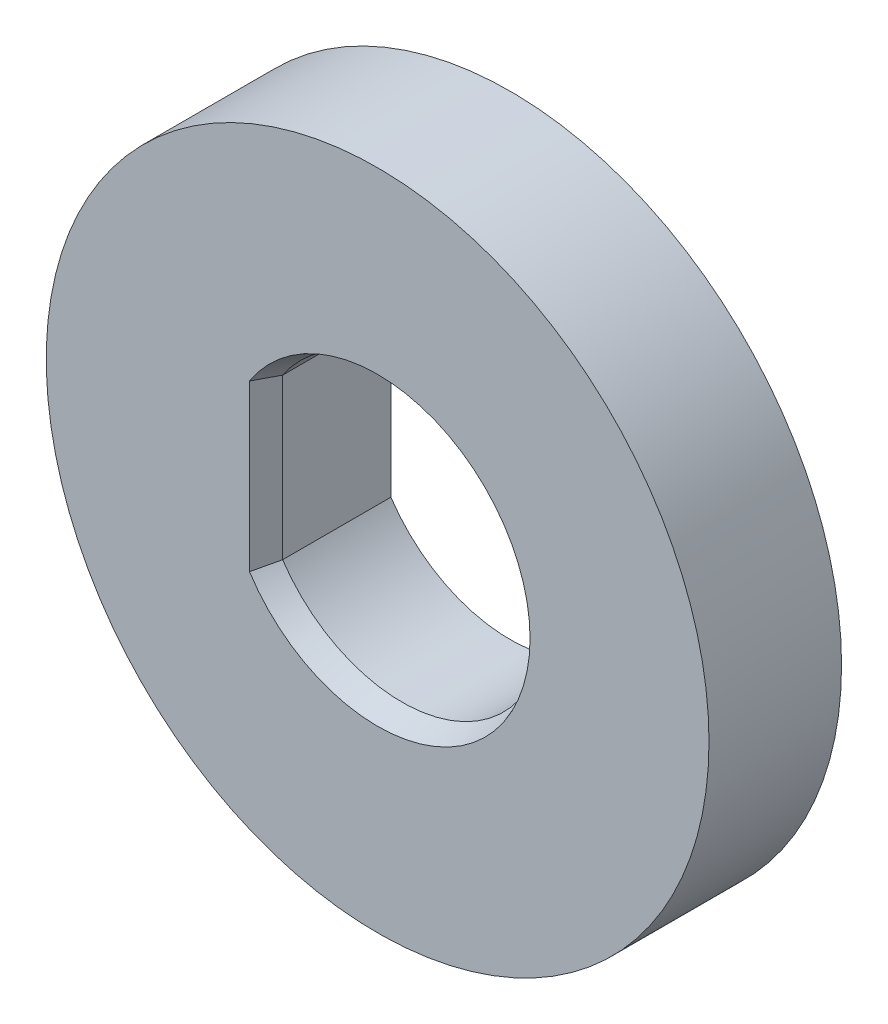
from build123d import *

# Parameters (mm, degrees)
SKETCH1_R           = 7.5
BOSS_EXTRUDE1_DEPTH = 3
CHAMFER3_SIZE       = 0.2
CHAMFER3_SIZE2      = 0.549495484


with BuildPart() as part:
    # Sketch1 → Boss-Extrude1 (new body)
    with BuildSketch(Plane.XY):
        Circle(SKETCH1_R)
        with BuildLine():
            Line((-2.7, -1.809005252), (-2.7, 1.809005252))
            ThreePointArc((-2.7, 1.809005252), (3.25, 0), (-2.7, -1.809005252))
        make_face(mode=Mode.SUBTRACT)
    extrude(amount=BOSS_EXTRUDE1_DEPTH)

    # Chamfer3
    chamfer3_edges = [part.edges().sort_by_distance(p)[0] for p in [
        (3.25, 0, 3),
        (-2.7, 0, 3),
    ]]
    chamfer3_side = [part.faces().sort_by_distance(p)[0] for p in [
        (-7.287867966, 0, 3),
    ]]
    chamfer(chamfer3_edges, length=CHAMFER3_SIZE, length2=CHAMFER3_SIZE2, reference=chamfer3_side[0])


solid = part.part
